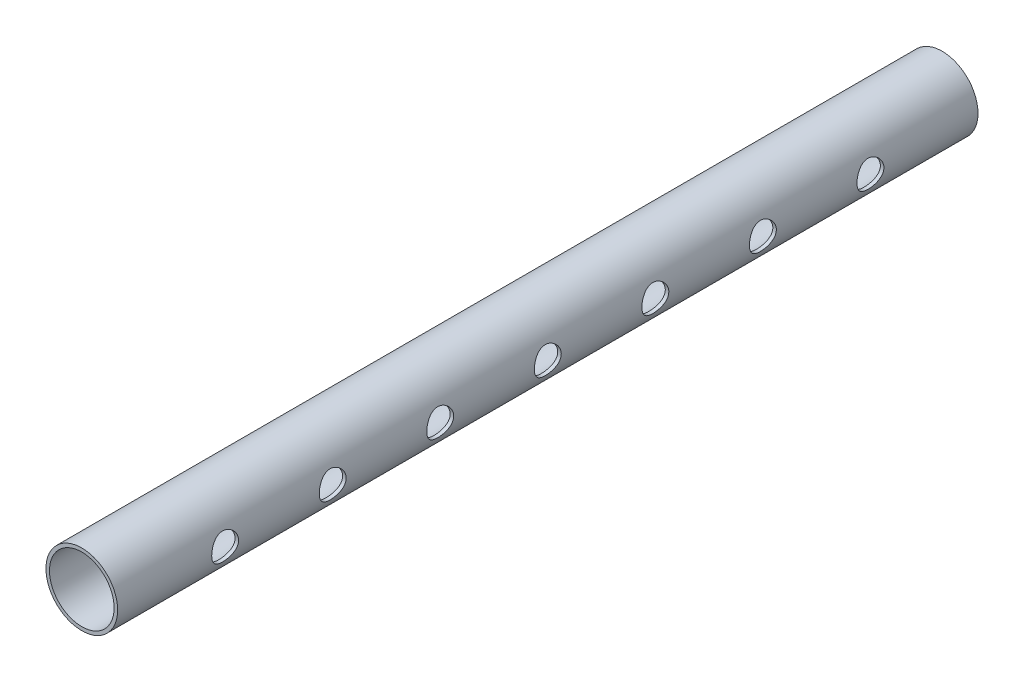
from build123d import *

# Parameters (mm, degrees)
SKETCH1_R           = 12.7
SKETCH1_R_2         = 11.4554
BOSS_EXTRUDE1_DEPTH = 152.4
SKETCH2_R           = 4.7625
CUT_EXTRUDE1_DEPTH  = 39.1


with BuildPart() as part:
    # Sketch1 → Boss-Extrude1 (new body, symmetric)
    with BuildSketch(Plane.XY):
        Circle(SKETCH1_R)
        Circle(SKETCH1_R_2, mode=Mode.SUBTRACT)
    extrude(amount=BOSS_EXTRUDE1_DEPTH, both=True)

    # Sketch2 → Cut-Extrude1 (cut, through all)
    with BuildSketch(Plane(origin=(25.4, 0, 0), x_dir=(0, 0, -1), z_dir=(1, 0, 0))):
        Circle(SKETCH2_R)
        with Locations((38.1, 0)):
            Circle(SKETCH2_R)
        with Locations((76.2, 0)):
            Circle(SKETCH2_R)
        with Locations((114.3, 0)):
            Circle(SKETCH2_R)
        with Locations((-38.1, 0)):
            Circle(SKETCH2_R)
        with Locations((-76.2, 0)):
            Circle(SKETCH2_R)
        with Locations((-114.3, 0)):
            Circle(SKETCH2_R)
    extrude(amount=-CUT_EXTRUDE1_DEPTH, mode=Mode.SUBTRACT)


solid = part.part
